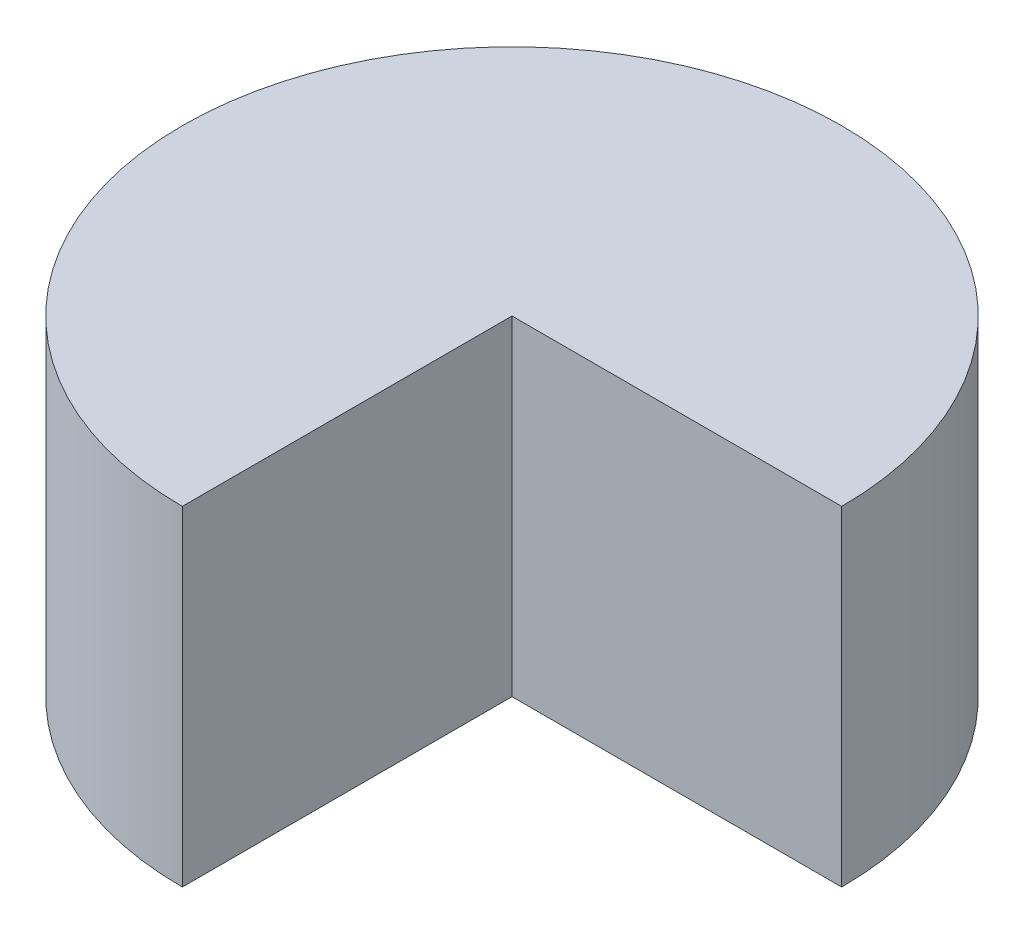
from build123d import *

# Parameters (mm, degrees)
BOSS_EXTRUDE1_DEPTH = 80
SHELL1_T            = -5


with BuildPart() as part:
    # Sketch2 → Boss-Extrude1 (new body)
    with BuildSketch(Plane(origin=(0, 0, 0), x_dir=(1, 0, 0), z_dir=(0, 1, 0))):
        with BuildLine():
            Line((0, 0), (80, 0))
            ThreePointArc((80, 0), (-56.568542495, 56.568542495), (0, -80))
            Line((0, -80), (0, 0))
        make_face()
    extrude(amount=BOSS_EXTRUDE1_DEPTH)

    # Shell1
    shell1_openings = [part.faces().sort_by_distance(p)[0] for p in [
        (-5.522847498, 0, -5.522847498),
    ]]
    offset(amount=SHELL1_T, openings=shell1_openings, kind=Kind.INTERSECTION)


solid = part.part
